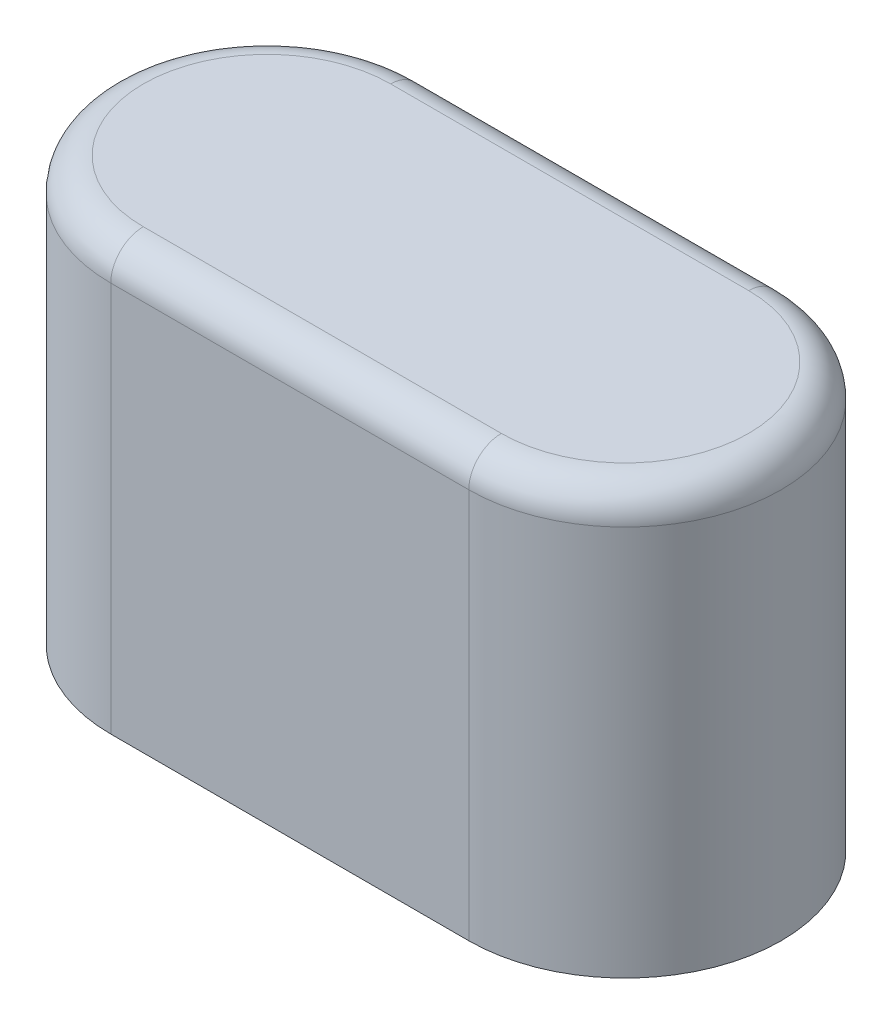
from build123d import *

# Parameters (mm, degrees)
BOSS_EXTRUDE1_DEPTH = 8.255
FILLET1_R           = 0.635
SKETCH2_R           = 1.778
CUT_EXTRUDE3_DEPTH  = 6.985


with BuildPart() as part:
    # Sketch1 → Boss-Extrude1 (new body)
    with BuildSketch(Plane(origin=(0, 0, 0), x_dir=(1, 0, 0), z_dir=(0, 1, 0))):
        with BuildLine():
            Line((-3.4925, 3.048), (3.4925, 3.048))
            ThreePointArc((3.4925, 3.048), (6.5405, 0), (3.4925, -3.048))
            Line((3.4925, -3.048), (-3.4925, -3.048))
            ThreePointArc((-3.4925, -3.048), (-6.5405, 0), (-3.4925, 3.048))
        make_face()
    extrude(amount=BOSS_EXTRUDE1_DEPTH)

    # Fillet1
    fillet1_edges = [part.edges().sort_by_distance(p)[0] for p in [
        (6.5405, 8.255, 0),
        (0, 8.255, -3.048),
        (-6.5405, 8.255, 0),
        (0, 8.255, 3.048),
    ]]
    fillet(fillet1_edges, radius=FILLET1_R)

    # Sketch2 → Cut-Extrude3 (cut)
    with BuildSketch(Plane.XZ):
        Circle(SKETCH2_R)
    extrude(amount=-CUT_EXTRUDE3_DEPTH, mode=Mode.SUBTRACT)


solid = part.part
